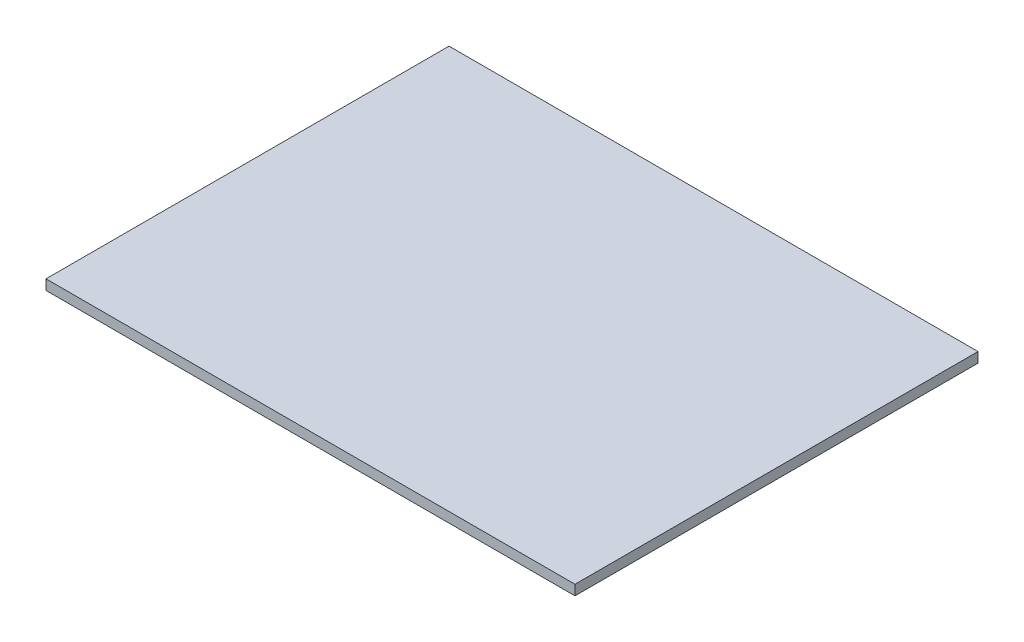
from build123d import *

# Parameters (mm, degrees)
SKETCH1_W           = 210
SKETCH1_H           = 160
BOSS_EXTRUDE1_DEPTH = 4


with BuildPart() as part:
    # Sketch1 → Boss-Extrude1 (new body)
    with BuildSketch(Plane(origin=(0, 0, 0), x_dir=(1, 0, 0), z_dir=(0, 1, 0))):
        Rectangle(SKETCH1_W, SKETCH1_H)
    extrude(amount=BOSS_EXTRUDE1_DEPTH)


solid = part.part
